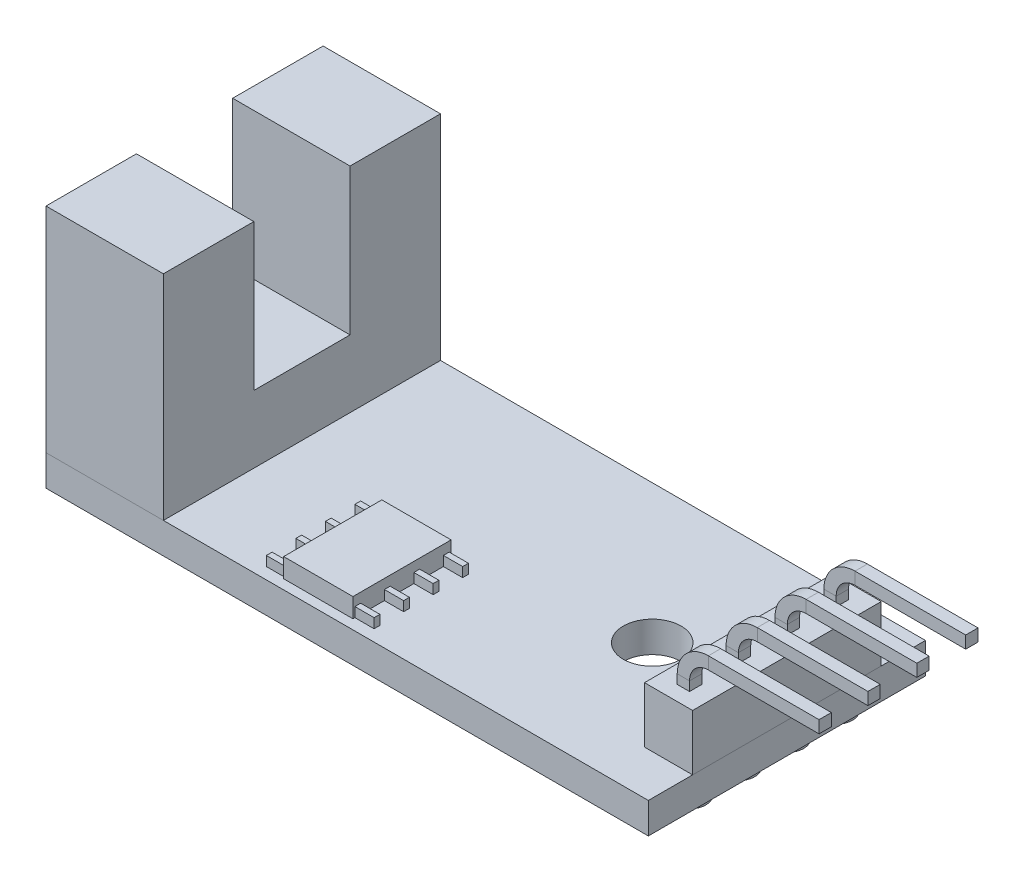
from build123d import *

# Parameters (mm, degrees)
CROQUIS1_W              = 31.3
CROQUIS1_H              = 14.4
CROQUIS1_R              = 1.5
BASE_DEPTH              = 1.6
CROQUIS2_W              = 2.5
CROQUIS2_H              = 9.8
BASE_PINES_DEPTH        = 2.9
SECCION_W               = 0.64
SECCION_H               = 0.64
MATRIZL1_COUNT          = 4
MATRIZL1_PITCH          = 2.54
CROQUIS5_W              = 6.1
CROQUIS5_H              = 14.4
CUERPO_SENSOR_DEPTH     = 11.1
CROQUIS6_W              = 6.1
CROQUIS6_H              = 5
AGUJERO_SENSOR_DEPTH    = 7.6
CROQUIS7_W              = 3.6
CROQUIS7_H              = 5.1
SALIENTE_EXTRUIR4_DEPTH = 1
CROQUIS8_W              = 1
CROQUIS8_H              = 0.3
SALIENTE_EXTRUIR5_DEPTH = 0.5
CROQUIS9_R              = 0.85
SALIENTE_EXTRUIR6_DEPTH = 0.5


with BuildPart() as part:
    # Croquis1 → BASE (new body)
    with BuildSketch(Plane(origin=(0, 0, 0), x_dir=(1, 0, 0), z_dir=(0, 1, 0))):
        Rectangle(CROQUIS1_W, CROQUIS1_H)
        with Locations((8.65, 0)):
            Circle(CROQUIS1_R, mode=Mode.SUBTRACT)
    extrude(amount=BASE_DEPTH)

    # Croquis9 → Saliente-Extruir6 (add)
    with BuildSketch(Plane.XZ):
        with Locations((-13.15, 5.15)):
            Circle(CROQUIS9_R)
        with Locations((-10.575, 5.15)):
            Circle(CROQUIS9_R)
        with Locations((-10.575, 2.575)):
            Circle(CROQUIS9_R)
        with Locations((-13.15, 2.575)):
            Circle(CROQUIS9_R)
        with Locations((-13.15, 0)):
            Circle(CROQUIS9_R)
        with Locations((-13.15, -2.575)):
            Circle(CROQUIS9_R)
        with Locations((-13.15, -5.15)):
            Circle(CROQUIS9_R)
        with Locations((-10.575, -5.15)):
            Circle(CROQUIS9_R)
        with Locations((-10.575, -2.575)):
            Circle(CROQUIS9_R)
        with Locations((14.4, 3.81)):
            Circle(CROQUIS9_R)
        with Locations((14.4, 1.27)):
            Circle(CROQUIS9_R)
        with Locations((14.4, -1.27)):
            Circle(CROQUIS9_R)
        with Locations((14.4, -3.81)):
            Circle(CROQUIS9_R)
    extrude(amount=SALIENTE_EXTRUIR6_DEPTH)


with BuildPart() as body_2:
    # Croquis2 → BASE PINES (new body)
    with BuildSketch(Plane(origin=(0, 1.6, 0), x_dir=(1, 0, 0), z_dir=(0, 1, 0))):
        with Locations((14.4, 0)):
            Rectangle(CROQUIS2_W, CROQUIS2_H)
    extrude(amount=BASE_PINES_DEPTH)


with BuildPart() as body_3:
    # PIN Vcc: sweep along a path in DIRECTRIZ
    with BuildLine(Plane.XY.offset(-3.81)) as pin_vcc_path:
        Line((14.4, 4.5), (14.4, 4.98))
        ThreePointArc((14.4, 4.98), (14.780761184, 5.899238816), (15.7, 6.28))
        Line((15.7, 6.28), (21.45, 6.28))
    # SECCION → PIN Vcc (sweep)
    with BuildSketch(Plane(origin=(0, 4.5, 0), x_dir=(1, 0, 0), z_dir=(0, 1, 0))):
        with Locations((14.4, 3.81)):
            Rectangle(SECCION_W, SECCION_H)
    sweep(path=pin_vcc_path.line)


with BuildPart() as matrizl1_1:
    # MatrizL1: pattern copy
    add(body_3.part.moved(Location(Vector(0, 0, 1) * (1 * MATRIZL1_PITCH))))


with BuildPart() as matrizl1_2:
    # MatrizL1: pattern copy
    add(body_3.part.moved(Location(Vector(0, 0, 1) * (2 * MATRIZL1_PITCH))))


with BuildPart() as matrizl1_3:
    # MatrizL1: pattern copy
    add(body_3.part.moved(Location(Vector(0, 0, 1) * (3 * MATRIZL1_PITCH))))


with BuildPart() as body_7:
    # Croquis5 → CUERPO SENSOR (new body)
    with BuildSketch(Plane(origin=(0, 1.6, 0), x_dir=(1, 0, 0), z_dir=(0, 1, 0))):
        with Locations((-12.6, 0)):
            Rectangle(CROQUIS5_W, CROQUIS5_H)
    extrude(amount=CUERPO_SENSOR_DEPTH)

    # Croquis6 → AGUJERO SENSOR (cut)
    with BuildSketch(Plane(origin=(0, 12.7, 0), x_dir=(1, 0, 0), z_dir=(0, 1, 0))):
        with Locations((-12.6, 0)):
            Rectangle(CROQUIS6_W, CROQUIS6_H)
    extrude(amount=-AGUJERO_SENSOR_DEPTH, mode=Mode.SUBTRACT)


with BuildPart() as body_8:
    # Croquis7 → Saliente-Extruir4 (new body)
    with BuildSketch(Plane(origin=(0, 1.6, 0), x_dir=(1, 0, 0), z_dir=(0, 1, 0))):
        with Locations((-2, -4.15)):
            Rectangle(CROQUIS7_W, CROQUIS7_H)
    extrude(amount=SALIENTE_EXTRUIR4_DEPTH)

    # Croquis8 → Saliente-Extruir5 (add)
    with BuildSketch(Plane(origin=(0, 1.6, 0), x_dir=(1, 0, 0), z_dir=(0, 1, 0))):
        with Locations((-4.3, -1.85)):
            Rectangle(CROQUIS8_W, CROQUIS8_H)
        with Locations((-4.3, -3.383333333)):
            Rectangle(CROQUIS8_W, CROQUIS8_H)
        with Locations((-4.3, -4.916666667)):
            Rectangle(CROQUIS8_W, CROQUIS8_H)
        with Locations((-4.3, -6.45)):
            Rectangle(CROQUIS8_W, CROQUIS8_H)
        with Locations((0.3, -1.85)):
            Rectangle(CROQUIS8_W, CROQUIS8_H)
        with Locations((0.3, -3.383333333)):
            Rectangle(CROQUIS8_W, CROQUIS8_H)
        with Locations((0.3, -4.916666667)):
            Rectangle(CROQUIS8_W, CROQUIS8_H)
        with Locations((0.3, -6.45)):
            Rectangle(CROQUIS8_W, CROQUIS8_H)
    extrude(amount=SALIENTE_EXTRUIR5_DEPTH)


solid = Compound([part.part, body_2.part, body_3.part, matrizl1_1.part, matrizl1_2.part, matrizl1_3.part, body_7.part, body_8.part])
